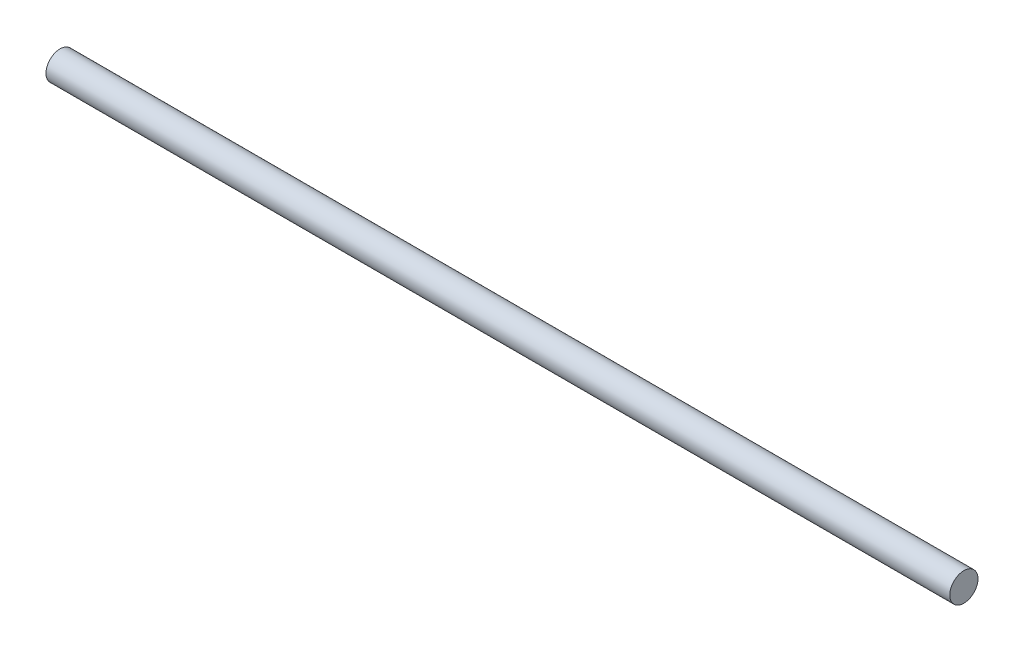
from build123d import *

# Parameters (mm, degrees)
SKETCH1_R           = 3.96875
BOSS_EXTRUDE1_DEPTH = 254


with BuildPart() as part:
    # Sketch1 → Boss-Extrude1 (new body)
    with BuildSketch(Plane(origin=(0, 0, 0), x_dir=(0, 0, -1), z_dir=(1, 0, 0))):
        Circle(SKETCH1_R)
    extrude(amount=BOSS_EXTRUDE1_DEPTH)


solid = part.part
